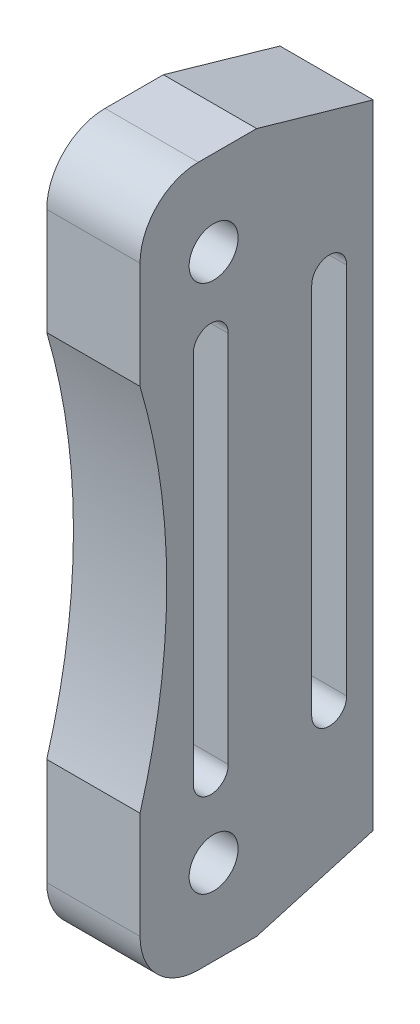
from build123d import *

# Parameters (mm, degrees)
SKETCH1_R             = 2.1
BOSS_EXTRUDE1_DEPTH   = 8
FILLET1_R             = 5
CHAMFER1_SIZE         = 10
CHAMFER1_SIZE2        = 2.867453858
CHAMFER1_PART_2_SIZE  = 10
CHAMFER1_PART_2_SIZE2 = 2.867453858
CUT_EXTRUDE1_REACH    = 10


with BuildPart() as part:
    # Sketch1 → Boss-Extrude1 (new body)
    with BuildSketch(Plane(origin=(0, 0, 0), x_dir=(0, 0, -1), z_dir=(1, 0, 0))):
        with BuildLine():
            Line((10, 30), (-10, 30))
            Line((-10, 30), (-10, 15.850422707))
            ThreePointArc((-10, 15.850422707), (-8.2854567, 8.007496488), (-7.71, 0))
            ThreePointArc((-7.71, 0), (-8.2854567, -8.007496488), (-10, -15.850422707))
            Line((-10, -15.850422707), (-10, -30))
            Line((-10, -30), (10, -30))
            Line((10, -30), (10, 30))
        make_face()
        with Locations((-3.69, -22.685)):
            Circle(SKETCH1_R, mode=Mode.SUBTRACT)
        with Locations((-3.69, 22.685)):
            Circle(SKETCH1_R, mode=Mode.SUBTRACT)
    extrude(amount=-BOSS_EXTRUDE1_DEPTH)

    # Fillet1
    fillet1_edges = [part.edges().sort_by_distance(p)[0] for p in [
        (-4, 30, 10),
        (-4, -30, 10),
    ]]
    fillet(fillet1_edges, radius=FILLET1_R)

    # Chamfer1
    chamfer1_edges = [part.edges().sort_by_distance(p)[0] for p in [
        (-4, 30, -10),
    ]]
    chamfer1_side = [part.faces().sort_by_distance(p)[0] for p in [
        (-4, 30, -2.5),
    ]]
    chamfer(chamfer1_edges, length=CHAMFER1_SIZE, length2=CHAMFER1_SIZE2, reference=chamfer1_side[0])

    # Chamfer1 part 2
    chamfer1_part_2_edges = [part.edges().sort_by_distance(p)[0] for p in [
        (-4, -30, -10),
    ]]
    chamfer1_part_2_side = [part.faces().sort_by_distance(p)[0] for p in [
        (-4, -30, -2.5),
    ]]
    chamfer(chamfer1_part_2_edges, length=CHAMFER1_PART_2_SIZE, length2=CHAMFER1_PART_2_SIZE2, reference=chamfer1_part_2_side[0])

    # Sketch2 → Cut-Extrude1 (cut, up to next)
    with BuildSketch(Plane(origin=(0, 0, 0), x_dir=(0, 0, -1), z_dir=(1, 0, 0)), mode=Mode.PRIVATE) as cut_extrude1_sk1:
        with BuildLine():
            Line((7.725, 16), (7.725, -16))
            ThreePointArc((7.725, -16), (6.225, -17.5), (4.725, -16))
            Line((4.725, -16), (4.725, 16))
            ThreePointArc((4.725, 16), (6.225, 17.5), (7.725, 16))
        make_face()
    cut_extrude1_tool1 = extrude(cut_extrude1_sk1.sketch, amount=-CUT_EXTRUDE1_REACH, mode=Mode.PRIVATE) & part.part
    add(cut_extrude1_tool1.solids().sort_by_distance((0, 0, -6.225))[0], mode=Mode.SUBTRACT)
    # Sketch2 → Cut-Extrude1 (cut, up to next)
    with BuildSketch(Plane(origin=(0, 0, 0), x_dir=(0, 0, -1), z_dir=(1, 0, 0)), mode=Mode.PRIVATE) as cut_extrude1_sk2:
        with BuildLine():
            Line((-5.435, 16), (-5.435, -16))
            ThreePointArc((-5.435, -16), (-3.935, -17.5), (-2.435, -16))
            Line((-2.435, -16), (-2.435, 16))
            ThreePointArc((-2.435, 16), (-3.935, 17.5), (-5.435, 16))
        make_face()
    cut_extrude1_tool2 = extrude(cut_extrude1_sk2.sketch, amount=-CUT_EXTRUDE1_REACH, mode=Mode.PRIVATE) & part.part
    add(cut_extrude1_tool2.solids().sort_by_distance((0, 0, 3.935))[0], mode=Mode.SUBTRACT)


solid = part.part
